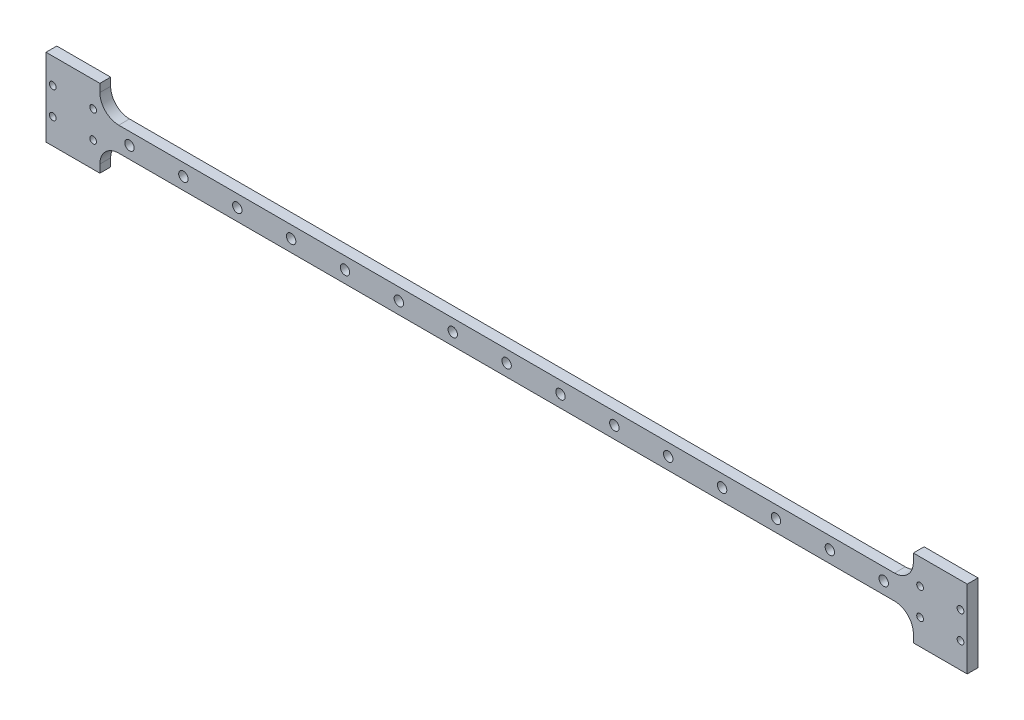
from build123d import *

# Parameters (mm, degrees)
SKETCH1_R           = 1.25
BOSS_EXTRUDE1_DEPTH = 4
FILLET1_R           = 7


with BuildPart() as part:
    # Sketch1 → Boss-Extrude1 (new body)
    with BuildSketch(Plane.XY):
        Polygon((-10, 14.45), (8.795857864, 14.45), (10, 14.45), (10, 4.5), (312, 4.5), (312, 14.45), (312.21, 14.45), (330.795857864, 14.45), (332, 14.45), (332, -14.45), (331.79, -14.45), (313.204142136, -14.45), (312, -14.45), (312, -4.5), (10, -4.5), (10, -14.45), (9.79, -14.45), (-8.795857864, -14.45), (-10, -14.45), (-10, -9.45), (-10, 9.45), align=None)
        with Locations((329.5, -5)):
            Circle(SKETCH1_R, mode=Mode.SUBTRACT)
        with Locations((314.5, 5)):
            Circle(SKETCH1_R, mode=Mode.SUBTRACT)
        with Locations((314.5, -5)):
            Circle(SKETCH1_R, mode=Mode.SUBTRACT)
        with Locations((329.5, 5)):
            Circle(SKETCH1_R, mode=Mode.SUBTRACT)
        with Locations((-7.5, -5)):
            Circle(SKETCH1_R, mode=Mode.SUBTRACT)
        with Locations((-7.5, 5)):
            Circle(SKETCH1_R, mode=Mode.SUBTRACT)
        with Locations((7.5, -5)):
            Circle(SKETCH1_R, mode=Mode.SUBTRACT)
        with Locations((7.5, 5)):
            Circle(SKETCH1_R, mode=Mode.SUBTRACT)
        with BuildLine():
            ThreePointArc((22.05, -1.4), (21, 1.75), (19.95, -1.4))
            ThreePointArc((19.95, -1.4), (21, -1.75), (22.05, -1.4))
        make_face(mode=Mode.SUBTRACT)
        with BuildLine():
            ThreePointArc((42.05, -1.4), (41, 1.75), (39.95, -1.4))
            ThreePointArc((39.95, -1.4), (41, -1.75), (42.05, -1.4))
        make_face(mode=Mode.SUBTRACT)
        with BuildLine():
            ThreePointArc((62.05, -1.4), (61, 1.75), (59.95, -1.4))
            ThreePointArc((59.95, -1.4), (61, -1.75), (62.05, -1.4))
        make_face(mode=Mode.SUBTRACT)
        with BuildLine():
            ThreePointArc((82.05, -1.4), (81, 1.75), (79.95, -1.4))
            ThreePointArc((79.95, -1.4), (81, -1.75), (82.05, -1.4))
        make_face(mode=Mode.SUBTRACT)
        with BuildLine():
            ThreePointArc((102.05, -1.4), (101, 1.75), (99.95, -1.4))
            ThreePointArc((99.95, -1.4), (101, -1.75), (102.05, -1.4))
        make_face(mode=Mode.SUBTRACT)
        with BuildLine():
            ThreePointArc((122.05, -1.4), (121, 1.75), (119.95, -1.4))
            ThreePointArc((119.95, -1.4), (121, -1.75), (122.05, -1.4))
        make_face(mode=Mode.SUBTRACT)
        with BuildLine():
            ThreePointArc((142.05, -1.4), (141, 1.75), (139.95, -1.4))
            ThreePointArc((139.95, -1.4), (141, -1.75), (142.05, -1.4))
        make_face(mode=Mode.SUBTRACT)
        with BuildLine():
            ThreePointArc((162.05, -1.4), (161, 1.75), (159.95, -1.4))
            ThreePointArc((159.95, -1.4), (161, -1.75), (162.05, -1.4))
        make_face(mode=Mode.SUBTRACT)
        with BuildLine():
            ThreePointArc((182.05, -1.4), (181, 1.75), (179.95, -1.4))
            ThreePointArc((179.95, -1.4), (181, -1.75), (182.05, -1.4))
        make_face(mode=Mode.SUBTRACT)
        with BuildLine():
            ThreePointArc((202.05, -1.4), (201, 1.75), (199.95, -1.4))
            ThreePointArc((199.95, -1.4), (201, -1.75), (202.05, -1.4))
        make_face(mode=Mode.SUBTRACT)
        with BuildLine():
            ThreePointArc((222.05, -1.4), (221, 1.75), (219.95, -1.4))
            ThreePointArc((219.95, -1.4), (221, -1.75), (222.05, -1.4))
        make_face(mode=Mode.SUBTRACT)
        with BuildLine():
            ThreePointArc((242.05, -1.4), (241, 1.75), (239.95, -1.4))
            ThreePointArc((239.95, -1.4), (241, -1.75), (242.05, -1.4))
        make_face(mode=Mode.SUBTRACT)
        with BuildLine():
            ThreePointArc((262.05, -1.4), (261, 1.75), (259.95, -1.4))
            ThreePointArc((259.95, -1.4), (261, -1.75), (262.05, -1.4))
        make_face(mode=Mode.SUBTRACT)
        with BuildLine():
            ThreePointArc((282.05, -1.4), (281, 1.75), (279.95, -1.4))
            ThreePointArc((279.95, -1.4), (281, -1.75), (282.05, -1.4))
        make_face(mode=Mode.SUBTRACT)
        with BuildLine():
            ThreePointArc((302.05, -1.4), (301, 1.75), (299.95, -1.4))
            ThreePointArc((299.95, -1.4), (301, -1.75), (302.05, -1.4))
        make_face(mode=Mode.SUBTRACT)
    extrude(amount=BOSS_EXTRUDE1_DEPTH)

    # Fillet1
    fillet1_edges = [part.edges().sort_by_distance(p)[0] for p in [
        (10, 4.5, 2),
        (312, 4.5, 2),
        (312, -4.5, 2),
        (10, -4.5, 2),
    ]]
    fillet(fillet1_edges, radius=FILLET1_R)


solid = part.part
